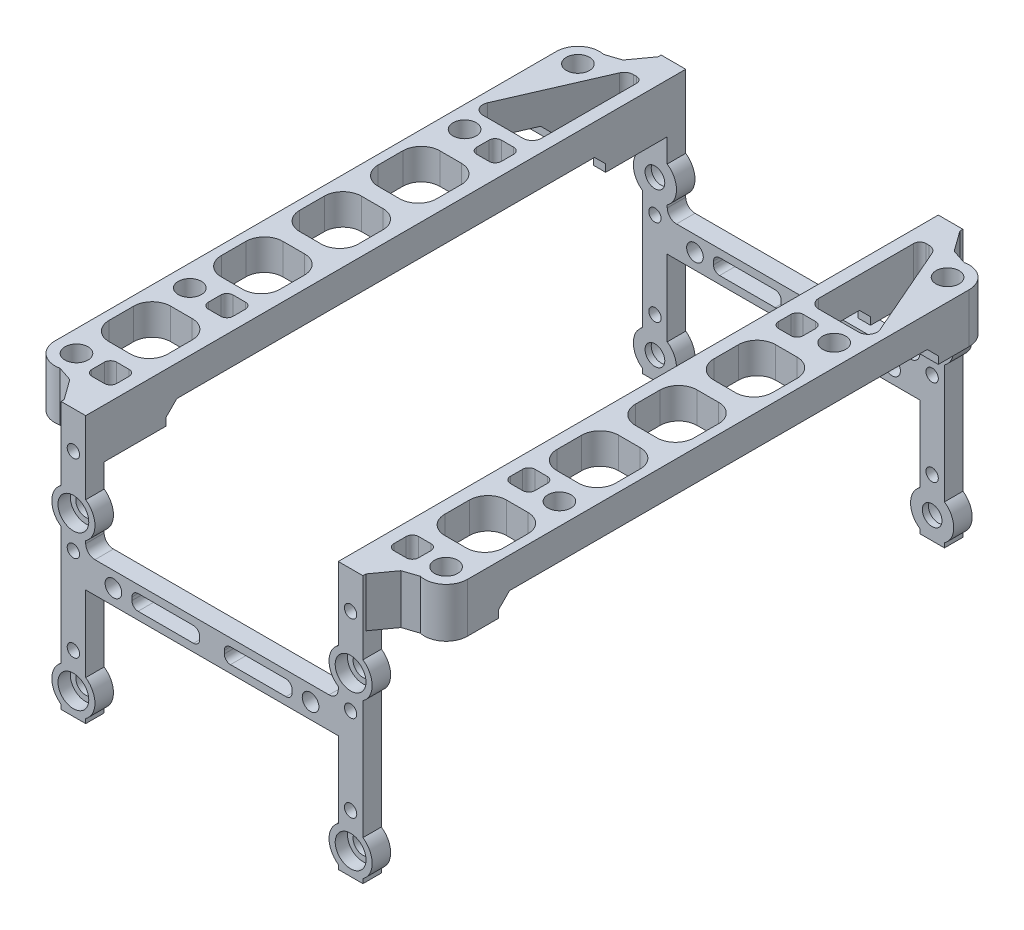
from build123d import *

# Parameters (mm, degrees)
BOSS_EXTRUDE1_DEPTH     = 4
SKETCH2_R               = 1.6
SKETCH2_R_2             = 1
CUT_EXTRUDE1_DEPTH      = 66.288436955
CUT_EXTRUDE1_DEPTH_BACK = 66.288436955
SKETCH3_W               = 20.5
SKETCH3_H               = 5
SKETCH3_R               = 1.35
BOSS_EXTRUDE2_DEPTH     = 3
BOSS_EXTRUDE3_DEPTH     = 8
SKETCH10_R              = 3.5
SKETCH10_R_2            = 1.6
BOSS_EXTRUDE5_DEPTH     = 3
SKETCH11_R              = 2.5
CUT_EXTRUDE4_DEPTH      = 2
SKETCH8_R               = 1.875
CUT_EXTRUDE3_DEPTH      = 118.056610236
CHAMFER1_SIZE           = 2.5
SKETCH12_R              = 3
CUT_EXTRUDE7_DEPTH      = 4.5
SKETCH13_W              = 71.4
SKETCH13_H              = 7.385436033
CUT_EXTRUDE8_DEPTH      = 124.593082331
CHAMFER4_SIZE           = 1.8
FILLET1_R               = 1.5


with BuildPart() as part:
    # Sketch1 → Boss-Extrude1 (new body)
    with BuildSketch(Plane(origin=(0, 0, 0), x_dir=(0, 0, -1), z_dir=(1, 0, 0))):
        Polygon((91.4, 35.3), (45.7, 35.3), (45.7, 43.3), (94.4, 43.3), (94.4, 0), (91.4, 0), align=None)
    extrude(amount=BOSS_EXTRUDE1_DEPTH)

    # Sketch2 → Cut-Extrude1 (cut, two sides)
    with BuildSketch(Plane.XY.offset(-94.4)) as cut_extrude1_sk:
        with Locations(Location((2, 28.6, 0), (0, 0, 90))):
            Circle(SKETCH2_R)
        with Locations(Location((2, 3.6, 0), (0, 0, 90))):
            Circle(SKETCH2_R)
        with Locations(Location((2, 37.3, 0), (0, 0, 90))):
            Circle(SKETCH2_R_2)
        with Locations(Location((2, 23.3, 0), (0, 0, 90))):
            Circle(SKETCH2_R_2)
        with Locations(Location((2, 9.3, 0), (0, 0, 90))):
            Circle(SKETCH2_R_2)
    extrude(amount=CUT_EXTRUDE1_DEPTH, mode=Mode.SUBTRACT)
    extrude(cut_extrude1_sk.sketch, amount=-CUT_EXTRUDE1_DEPTH_BACK, mode=Mode.SUBTRACT)

    # Sketch3 → Boss-Extrude2 (add)
    with BuildSketch(Plane(origin=(0, 0, -94.4), x_dir=(-1, 0, 0), z_dir=(0, 0, -1))):
        with Locations((10.25, 21.3)):
            Rectangle(SKETCH3_W, SKETCH3_H)
        with Locations(Location((4.5, 21.3, 0), (0, 0, 90))):
            Circle(SKETCH3_R, mode=Mode.SUBTRACT)
        with BuildLine():
            ThreePointArc((7.5, 21.55), (7.792893219, 22.257106781), (8.5, 22.55))
            Line((8.5, 22.55), (17.5, 22.55))
            ThreePointArc((17.5, 22.55), (18.207106781, 22.257106781), (18.5, 21.55))
            Line((18.5, 21.55), (18.5, 21.05))
            ThreePointArc((18.5, 21.05), (18.207106781, 20.342893219), (17.5, 20.05))
            Line((17.5, 20.05), (8.5, 20.05))
            ThreePointArc((8.5, 20.05), (7.792893219, 20.342893219), (7.5, 21.05))
            Line((7.5, 21.05), (7.5, 21.55))
        make_face(mode=Mode.SUBTRACT)
        with BuildLine():
            Line((0, 27.1), (0, 25.727718677))
            ThreePointArc((0, 25.727718677), (1.5, 28.6), (0, 31.472281323))
            Line((0, 31.472281323), (0, 30.1))
            ThreePointArc((0, 30.1), (0.5, 28.6), (0, 27.1))
        make_face()
        with BuildLine():
            ThreePointArc((-4, 31.472281323), (-5.5, 28.6), (-4, 25.727718677))
            Line((-4, 25.727718677), (-4, 27.1))
            ThreePointArc((-4, 27.1), (-4.5, 28.6), (-4, 30.1))
            Line((-4, 30.1), (-4, 31.472281323))
        make_face()
    extrude(amount=-BOSS_EXTRUDE2_DEPTH)

    # Sketch5 → Boss-Extrude3 (add)
    with BuildSketch(Plane(origin=(0, 43.3, 0), x_dir=(1, 0, 0), z_dir=(0, 1, 0))):
        with BuildLine():
            Line((4, 91.4), (8.746327496, 89.817890835))
            ThreePointArc((8.746327496, 89.817890835), (11.692275785, 89.128356077), (13, 86.4))
            Line((13, 86.4), (13, 45.7))
            Line((13, 45.7), (0, 45.7))
            Line((0, 45.7), (0, 91.4))
            Line((0, 91.4), (4, 91.4))
        make_face()
    extrude(amount=-BOSS_EXTRUDE3_DEPTH)

    # Sketch10 → Boss-Extrude5 (add)
    with BuildSketch(Plane(origin=(0, 0, -94.4), x_dir=(-1, 0, 0), z_dir=(0, 0, -1))):
        with Locations((-2, 28.6)):
            Circle(SKETCH10_R)
        with Locations(Location((-2, 28.6, 0), (0, 0, 90))):
            Circle(SKETCH10_R_2, mode=Mode.SUBTRACT)
        with Locations((-2, 3.6)):
            Circle(SKETCH10_R)
        with Locations(Location((-2, 3.6, 0), (0, 0, 90))):
            Circle(SKETCH10_R_2, mode=Mode.SUBTRACT)
    extrude(amount=-BOSS_EXTRUDE5_DEPTH)

    # Sketch11 → Cut-Extrude4 (cut)
    with BuildSketch(Plane(origin=(0, 0, -94.4), x_dir=(-1, 0, 0), z_dir=(0, 0, -1))):
        with Locations(Location((-2, 28.6, 0), (0, 0, 90))):
            Circle(SKETCH11_R)
        with Locations(Location((-2, 3.6, 0), (0, 0, 90))):
            Circle(SKETCH11_R)
    extrude(amount=-CUT_EXTRUDE4_DEPTH, mode=Mode.SUBTRACT)

    # Mirror4: part across plane


with BuildPart() as part_1:
    add(part.part)
    add(part.part.mirror(Plane.ZY.offset(20.5)))

    # Mirror5: part across plane


with BuildPart() as part_2:
    add(part_1.part)
    add(part_1.part.mirror(Plane(origin=(4, 0, -45.7), x_dir=(1, 0, 0), z_dir=(0, 0, -1))))

    # Sketch8 → Cut-Extrude3 (cut, through all)
    with BuildSketch(Plane(origin=(0, 43.3, 0), x_dir=(1, 0, 0), z_dir=(0, 1, 0))):
        with Locations(Location((9.5, 86.4, 0), (0, 0, 270))):
            Circle(SKETCH8_R)
        with Locations(Location((9.5, 5, 0), (0, 0, 270))):
            Circle(SKETCH8_R)
        with Locations(Location((9.5, 23.4, 0), (0, 0, 270))):
            Circle(SKETCH8_R)
        with Locations(Location((9.5, 68, 0), (0, 0, 270))):
            Circle(SKETCH8_R)
        with Locations(Location((-50.5, 68, 0), (0, 0, 90))):
            Circle(SKETCH8_R)
        with Locations(Location((-50.5, 23.4, 0), (0, 0, 90))):
            Circle(SKETCH8_R)
        with Locations(Location((-50.5, 5, 0), (0, 0, 90))):
            Circle(SKETCH8_R)
        with Locations(Location((-50.5, 86.4, 0), (0, 0, 90))):
            Circle(SKETCH8_R)
        with BuildLine():
            Line((5, 50.241463908), (8.5, 50.241463908))
            ThreePointArc((8.5, 50.241463908), (10.621320344, 49.362784251), (11.5, 47.241463908))
            Line((11.5, 47.241463908), (11.5, 43.241463908))
            ThreePointArc((11.5, 43.241463908), (10.621320344, 41.120143564), (8.5, 40.241463908))
            Line((8.5, 40.241463908), (5, 40.241463908))
            ThreePointArc((5, 40.241463908), (2.878679656, 41.120143564), (2, 43.241463908))
            Line((2, 43.241463908), (2, 47.241463908))
            ThreePointArc((2, 47.241463908), (2.878679656, 49.362784251), (5, 50.241463908))
        make_face()
        with BuildLine():
            Line((5, 62.974937186), (8.5, 62.974937186))
            ThreePointArc((8.5, 62.974937186), (10.621320344, 62.096257529), (11.5, 59.974937186))
            Line((11.5, 59.974937186), (11.5, 55.974937186))
            ThreePointArc((11.5, 55.974937186), (10.621320344, 53.853616842), (8.5, 52.974937186))
            Line((8.5, 52.974937186), (5, 52.974937186))
            ThreePointArc((5, 52.974937186), (2.878679656, 53.853616842), (2, 55.974937186))
            Line((2, 55.974937186), (2, 59.974937186))
            ThreePointArc((2, 59.974937186), (2.878679656, 62.096257529), (5, 62.974937186))
        make_face()
        with BuildLine():
            Line((2, 88.4), (2, 72.974937186))
            ThreePointArc((2, 72.974937186), (2.439339828, 71.914277014), (3.5, 71.474937186))
            Line((3.5, 71.474937186), (10, 71.474937186))
            ThreePointArc((10, 71.474937186), (11.254670055, 72.152864772), (11.37523952, 73.573866449))
            Line((11.37523952, 73.573866449), (4.87523952, 88.498929264))
            ThreePointArc((4.87523952, 88.498929264), (4.322072413, 89.154670055), (3.5, 89.4))
            Line((3.5, 89.4), (3, 89.4))
            ThreePointArc((3, 89.4), (2.292893219, 89.107106781), (2, 88.4))
        make_face()
        with BuildLine():
            Line((3, 69.474937186), (5, 69.474937186))
            ThreePointArc((5, 69.474937186), (5.707106781, 69.182043967), (6, 68.474937186))
            Line((6, 68.474937186), (6, 66.474937186))
            ThreePointArc((6, 66.474937186), (5.707106781, 65.767830404), (5, 65.474937186))
            Line((5, 65.474937186), (3, 65.474937186))
            ThreePointArc((3, 65.474937186), (2.292893219, 65.767830404), (2, 66.474937186))
            Line((2, 66.474937186), (2, 68.474937186))
            ThreePointArc((2, 68.474937186), (2.292893219, 69.182043967), (3, 69.474937186))
        make_face()
        with BuildLine():
            Line((5, 37.50799063), (8.5, 37.50799063))
            ThreePointArc((8.5, 37.50799063), (10.621320344, 36.629310973), (11.5, 34.50799063))
            Line((11.5, 34.50799063), (11.5, 30.50799063))
            ThreePointArc((11.5, 30.50799063), (10.621320344, 28.386670286), (8.5, 27.50799063))
            Line((8.5, 27.50799063), (5, 27.50799063))
            ThreePointArc((5, 27.50799063), (2.878679656, 28.386670286), (2, 30.50799063))
            Line((2, 30.50799063), (2, 34.50799063))
            ThreePointArc((2, 34.50799063), (2.878679656, 36.629310973), (5, 37.50799063))
        make_face()
        with BuildLine():
            Line((6, 22.925062814), (6, 24.925062814))
            ThreePointArc((6, 24.925062814), (5.707106781, 25.632169596), (5, 25.925062814))
            Line((5, 25.925062814), (3, 25.925062814))
            ThreePointArc((3, 25.925062814), (2.292893219, 25.632169596), (2, 24.925062814))
            Line((2, 24.925062814), (2, 22.925062814))
            ThreePointArc((2, 22.925062814), (2.292893219, 22.217956033), (3, 21.925062814))
            Line((3, 21.925062814), (5, 21.925062814))
            ThreePointArc((5, 21.925062814), (5.707106781, 22.217956033), (6, 22.925062814))
        make_face()
        with BuildLine():
            Line((11.5, 12.29200937), (11.5, 16.29200937))
            ThreePointArc((11.5, 16.29200937), (10.621320344, 18.413329714), (8.5, 19.29200937))
            Line((8.5, 19.29200937), (5, 19.29200937))
            ThreePointArc((5, 19.29200937), (2.878679656, 18.413329714), (2, 16.29200937))
            Line((2, 16.29200937), (2, 12.29200937))
            ThreePointArc((2, 12.29200937), (2.878679656, 10.170689027), (5, 9.29200937))
            Line((5, 9.29200937), (8.5, 9.29200937))
            ThreePointArc((8.5, 9.29200937), (10.621320344, 10.170689027), (11.5, 12.29200937))
        make_face()
        with BuildLine():
            Line((-46, 9.29200937), (-49.5, 9.29200937))
            ThreePointArc((-49.5, 9.29200937), (-51.621320344, 10.170689027), (-52.5, 12.29200937))
            Line((-52.5, 12.29200937), (-52.5, 16.29200937))
            ThreePointArc((-52.5, 16.29200937), (-51.621320344, 18.413329714), (-49.5, 19.29200937))
            Line((-49.5, 19.29200937), (-46, 19.29200937))
            ThreePointArc((-46, 19.29200937), (-43.878679656, 18.413329714), (-43, 16.29200937))
            Line((-43, 16.29200937), (-43, 12.29200937))
            ThreePointArc((-43, 12.29200937), (-43.878679656, 10.170689027), (-46, 9.29200937))
        make_face()
        with BuildLine():
            Line((-44, 21.925062814), (-46, 21.925062814))
            ThreePointArc((-46, 21.925062814), (-46.707106781, 22.217956033), (-47, 22.925062814))
            Line((-47, 22.925062814), (-47, 24.925062814))
            ThreePointArc((-47, 24.925062814), (-46.707106781, 25.632169596), (-46, 25.925062814))
            Line((-46, 25.925062814), (-44, 25.925062814))
            ThreePointArc((-44, 25.925062814), (-43.292893219, 25.632169596), (-43, 24.925062814))
            Line((-43, 24.925062814), (-43, 22.925062814))
            ThreePointArc((-43, 22.925062814), (-43.292893219, 22.217956033), (-44, 21.925062814))
        make_face()
        with BuildLine():
            Line((-52.5, 34.50799063), (-52.5, 30.50799063))
            ThreePointArc((-52.5, 30.50799063), (-51.621320344, 28.386670286), (-49.5, 27.50799063))
            Line((-49.5, 27.50799063), (-46, 27.50799063))
            ThreePointArc((-46, 27.50799063), (-43.878679656, 28.386670286), (-43, 30.50799063))
            Line((-43, 30.50799063), (-43, 34.50799063))
            ThreePointArc((-43, 34.50799063), (-43.878679656, 36.629310973), (-46, 37.50799063))
            Line((-46, 37.50799063), (-49.5, 37.50799063))
            ThreePointArc((-49.5, 37.50799063), (-51.621320344, 36.629310973), (-52.5, 34.50799063))
        make_face()
        with BuildLine():
            Line((-52.5, 47.241463908), (-52.5, 43.241463908))
            ThreePointArc((-52.5, 43.241463908), (-51.621320344, 41.120143564), (-49.5, 40.241463908))
            Line((-49.5, 40.241463908), (-46, 40.241463908))
            ThreePointArc((-46, 40.241463908), (-43.878679656, 41.120143564), (-43, 43.241463908))
            Line((-43, 43.241463908), (-43, 47.241463908))
            ThreePointArc((-43, 47.241463908), (-43.878679656, 49.362784251), (-46, 50.241463908))
            Line((-46, 50.241463908), (-49.5, 50.241463908))
            ThreePointArc((-49.5, 50.241463908), (-51.621320344, 49.362784251), (-52.5, 47.241463908))
        make_face()
        with BuildLine():
            Line((-47, 68.474937186), (-47, 66.474937186))
            ThreePointArc((-47, 66.474937186), (-46.707106781, 65.767830404), (-46, 65.474937186))
            Line((-46, 65.474937186), (-44, 65.474937186))
            ThreePointArc((-44, 65.474937186), (-43.292893219, 65.767830404), (-43, 66.474937186))
            Line((-43, 66.474937186), (-43, 68.474937186))
            ThreePointArc((-43, 68.474937186), (-43.292893219, 69.182043967), (-44, 69.474937186))
            Line((-44, 69.474937186), (-46, 69.474937186))
            ThreePointArc((-46, 69.474937186), (-46.707106781, 69.182043967), (-47, 68.474937186))
        make_face()
        with BuildLine():
            Line((-52.5, 59.974937186), (-52.5, 55.974937186))
            ThreePointArc((-52.5, 55.974937186), (-51.621320344, 53.853616842), (-49.5, 52.974937186))
            Line((-49.5, 52.974937186), (-46, 52.974937186))
            ThreePointArc((-46, 52.974937186), (-43.878679656, 53.853616842), (-43, 55.974937186))
            Line((-43, 55.974937186), (-43, 59.974937186))
            ThreePointArc((-43, 59.974937186), (-43.878679656, 62.096257529), (-46, 62.974937186))
            Line((-46, 62.974937186), (-49.5, 62.974937186))
            ThreePointArc((-49.5, 62.974937186), (-51.621320344, 62.096257529), (-52.5, 59.974937186))
        make_face()
        with BuildLine():
            Line((-44.5, 89.4), (-44, 89.4))
            ThreePointArc((-44, 89.4), (-43.292893219, 89.107106781), (-43, 88.4))
            Line((-43, 88.4), (-43, 72.974937186))
            ThreePointArc((-43, 72.974937186), (-43.439339828, 71.914277014), (-44.5, 71.474937186))
            Line((-44.5, 71.474937186), (-51, 71.474937186))
            ThreePointArc((-51, 71.474937186), (-52.254670055, 72.152864772), (-52.37523952, 73.573866449))
            Line((-52.37523952, 73.573866449), (-45.87523952, 88.498929264))
            ThreePointArc((-45.87523952, 88.498929264), (-45.322072413, 89.154670055), (-44.5, 89.4))
        make_face()
        with BuildLine():
            Line((6, 3.969434758), (6, 6.030565242))
            ThreePointArc((6, 6.030565242), (5.707106781, 6.737672023), (5, 7.030565242))
            Line((5, 7.030565242), (3, 7.030565242))
            ThreePointArc((3, 7.030565242), (2.292893219, 6.737672023), (2, 6.030565242))
            Line((2, 6.030565242), (2, 4.030565242))
            ThreePointArc((2, 4.030565242), (2.292893219, 3.323458461), (3, 3.030565242))
            Line((3, 3.030565242), (5, 3.030565242))
            ThreePointArc((5, 3.030565242), (5.686342446, 3.30152466), (6, 3.969434758))
        make_face()
        with BuildLine():
            Line((-44, 3.030565242), (-46, 3.030565242))
            ThreePointArc((-46, 3.030565242), (-46.686342446, 3.30152466), (-47, 3.969434758))
            Line((-47, 3.969434758), (-47, 6.030565242))
            ThreePointArc((-47, 6.030565242), (-46.707106781, 6.737672023), (-46, 7.030565242))
            Line((-46, 7.030565242), (-44, 7.030565242))
            ThreePointArc((-44, 7.030565242), (-43.292893219, 6.737672023), (-43, 6.030565242))
            Line((-43, 6.030565242), (-43, 4.030565242))
            ThreePointArc((-43, 4.030565242), (-43.292893219, 3.323458461), (-44, 3.030565242))
        make_face()
    extrude(amount=-CUT_EXTRUDE3_DEPTH, mode=Mode.SUBTRACT)

    # Chamfer1
    chamfer1_edges = [part_2.edges().sort_by_distance(p)[0] for p in [
        (4, 39.3, -91.4),
        (-45, 39.3, -91.4),
        (4, 39.3, 0),
        (-45, 39.3, 0),
    ]]
    chamfer(chamfer1_edges, length=CHAMFER1_SIZE)

    # Sketch12 → Cut-Extrude7 (cut)
    with BuildSketch(Plane.XZ.offset(-35.3)):
        with Locations(Location((9.5, -5, 0), (0, 0, 270))):
            Circle(SKETCH12_R)
        with Locations(Location((9.5, -23.4, 0), (0, 0, 270))):
            Circle(SKETCH12_R)
        with Locations(Location((9.5, -86.4, 0), (0, 0, 90))):
            Circle(SKETCH12_R)
        with Locations(Location((9.5, -68, 0), (0, 0, 90))):
            Circle(SKETCH12_R)
        with Locations(Location((-50.5, -86.4, 0), (0, 0, 270))):
            Circle(SKETCH12_R)
        with Locations(Location((-50.5, -68, 0), (0, 0, 270))):
            Circle(SKETCH12_R)
        with Locations(Location((-50.5, -23.4, 0), (0, 0, 90))):
            Circle(SKETCH12_R)
        with Locations(Location((-50.5, -5, 0), (0, 0, 90))):
            Circle(SKETCH12_R)
    extrude(amount=-CUT_EXTRUDE7_DEPTH, mode=Mode.SUBTRACT)

    # Sketch13 → Cut-Extrude8 (cut, through all)
    with BuildSketch(Plane.ZY.offset(54)):
        with Locations((-45.7, 34.607281984)):
            Rectangle(SKETCH13_W, SKETCH13_H)
    extrude(amount=-CUT_EXTRUDE8_DEPTH, mode=Mode.SUBTRACT)

    # Chamfer4
    chamfer4_edges = [part_2.edges().sort_by_distance(p)[0] for p in [
        (-42.532181183, 38.3, -10),
        (-52.717818817, 38.3, -10),
        (1.532181183, 38.3, -10),
        (1, 38.3, -81.4),
        (10.483443747, 38.3, -81.4),
        (-42, 38.3, -81.4),
        (-51.483443747, 38.3, -81.4),
        (11.717818817, 38.3, -10),
    ]]
    chamfer(chamfer4_edges, length=CHAMFER4_SIZE)

    # Fillet1
    fillet1_edges = [part_2.edges().sort_by_distance(p)[0] for p in [
        (-41, 23.8, -92.9),
        (0, 23.8, 1.5),
        (-41, 23.8, 1.5),
        (0, 23.8, -92.9),
    ]]
    fillet(fillet1_edges, radius=FILLET1_R)


solid = part_2.part
